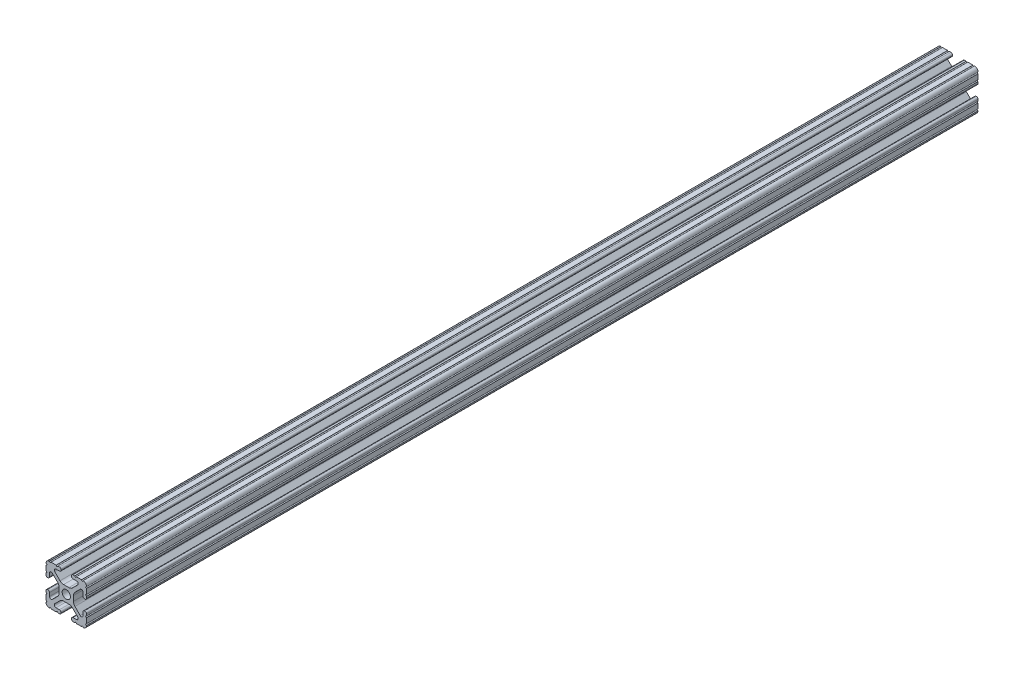
from build123d import *

# Parameters (mm, degrees)
SKETCH1_R           = 2.6035
BOSS_EXTRUDE1_DEPTH = 279.4


with BuildPart() as part:
    # Sketch1 → Boss-Extrude1 (new body, symmetric)
    with BuildSketch(Plane.XY):
        with BuildLine():
            Line((-7.179650497, -8.645192506), (-3.952270251, -5.423690499))
            ThreePointArc((-3.952270251, -5.423690499), (-2.922936451, -4.736929036), (-1.709253557, -4.4958))
            Line((-1.709253557, -4.4958), (1.709253557, -4.4958))
            ThreePointArc((1.709253557, -4.4958), (2.922936451, -4.736929036), (3.952270251, -5.423690499))
            Line((3.952270251, -5.423690499), (7.179650497, -8.645192506))
            ThreePointArc((7.179650497, -8.645192506), (7.41473083, -9.822813117), (6.416408329, -10.4902))
            Line((6.416408329, -10.4902), (4.287512407, -10.4902))
            ThreePointArc((4.287512407, -10.4902), (3.54574862, -10.79744862), (3.2385, -11.539212407))
            Line((3.2385, -11.539212407), (3.2385, -11.650987593))
            ThreePointArc((3.2385, -11.650987593), (3.54574862, -12.39275138), (4.287512407, -12.7))
            Line((4.287512407, -12.7), (5.317126718, -12.7))
            ThreePointArc((5.317126718, -12.7), (5.825126718, -12.192), (6.333126718, -12.7))
            Line((6.333126718, -12.7), (9.550443118, -12.7))
            ThreePointArc((9.550443118, -12.7), (10.058366869, -12.192000006), (10.566443095, -12.699847501))
            ThreePointArc((10.566443095, -12.699847501), (12.082537762, -12.08250727), (12.699846982, -10.566399977))
            ThreePointArc((12.699846982, -10.566399977), (12.192000006, -10.058323491), (12.7, -9.5504))
            Line((12.7, -9.5504), (12.7, -6.3330836))
            ThreePointArc((12.7, -6.3330836), (12.192, -5.8250836), (12.7, -5.3170836))
            Line((12.7, -5.3170836), (12.7, -4.287469289))
            ThreePointArc((12.7, -4.287469289), (12.39275138, -3.545705502), (11.650987593, -3.238456882))
            Line((11.650987593, -3.238456882), (11.539212407, -3.238456882))
            ThreePointArc((11.539212407, -3.238456882), (10.79744862, -3.545705502), (10.4902, -4.287469289))
            Line((10.4902, -4.287469289), (10.4902, -6.402089023))
            ThreePointArc((10.4902, -6.402089023), (9.856505071, -7.351067942), (8.737131347, -7.129408934))
            Line((8.737131347, -7.129408934), (5.441005833, -3.840816462))
            ThreePointArc((5.441005833, -3.840816462), (4.750877967, -2.809883091), (4.5085, -1.593185507))
            Line((4.5085, -1.593185507), (4.5085, 1.593185507))
            ThreePointArc((4.5085, 1.593185507), (4.750877967, 2.809883091), (5.441005833, 3.840816462))
            Line((5.441005833, 3.840816462), (8.737131347, 7.129408934))
            ThreePointArc((8.737131347, 7.129408934), (9.856505071, 7.351067942), (10.4902, 6.402089023))
            Line((10.4902, 6.402089023), (10.4902, 4.287469289))
            ThreePointArc((10.4902, 4.287469289), (10.79744862, 3.545705502), (11.539212407, 3.238456882))
            Line((11.539212407, 3.238456882), (11.650987593, 3.238456882))
            ThreePointArc((11.650987593, 3.238456882), (12.39275138, 3.545705502), (12.7, 4.287469289))
            Line((12.7, 4.287469289), (12.7, 5.3170836))
            ThreePointArc((12.7, 5.3170836), (12.192, 5.8250836), (12.7, 6.3330836))
            Line((12.7, 6.3330836), (12.7, 9.5504))
            ThreePointArc((12.7, 9.5504), (12.192000006, 10.058323491), (12.699846982, 10.566399977))
            ThreePointArc((12.699846982, 10.566399977), (12.082537762, 12.08250727), (10.566443095, 12.699847501))
            ThreePointArc((10.566443095, 12.699847501), (10.058366869, 12.192000006), (9.550443118, 12.7))
            Line((9.550443118, 12.7), (6.333126718, 12.7))
            ThreePointArc((6.333126718, 12.7), (5.825126718, 12.192), (5.317126718, 12.7))
            Line((5.317126718, 12.7), (4.287512407, 12.7))
            ThreePointArc((4.287512407, 12.7), (3.54574862, 12.39275138), (3.2385, 11.650987593))
            Line((3.2385, 11.650987593), (3.2385, 11.539212407))
            ThreePointArc((3.2385, 11.539212407), (3.54574862, 10.79744862), (4.287512407, 10.4902))
            Line((4.287512407, 10.4902), (6.476788598, 10.4902))
            ThreePointArc((6.476788598, 10.4902), (7.432222385, 9.85140422), (7.207036008, 8.724370562))
            Line((7.207036008, 8.724370562), (3.898272566, 5.423169045))
            ThreePointArc((3.898272566, 5.423169045), (2.869120213, 4.736787962), (1.655778399, 4.4958))
            Line((1.655778399, 4.4958), (-1.655778399, 4.4958))
            ThreePointArc((-1.655778399, 4.4958), (-2.869120213, 4.736787962), (-3.898272566, 5.423169045))
            Line((-3.898272566, 5.423169045), (-7.207036008, 8.724370562))
            ThreePointArc((-7.207036008, 8.724370562), (-7.432222385, 9.85140422), (-6.476788598, 10.4902))
            Line((-6.476788598, 10.4902), (-4.287512407, 10.4902))
            ThreePointArc((-4.287512407, 10.4902), (-3.54574862, 10.79744862), (-3.2385, 11.539212407))
            Line((-3.2385, 11.539212407), (-3.2385, 11.650987593))
            ThreePointArc((-3.2385, 11.650987593), (-3.54574862, 12.39275138), (-4.287512407, 12.7))
            Line((-4.287512407, 12.7), (-5.317126718, 12.7))
            ThreePointArc((-5.317126718, 12.7), (-5.825126718, 12.192), (-6.333126718, 12.7))
            Line((-6.333126718, 12.7), (-9.550443118, 12.7))
            ThreePointArc((-9.550443118, 12.7), (-10.058366869, 12.192000006), (-10.566443095, 12.699847501))
            ThreePointArc((-10.566443095, 12.699847501), (-12.082537762, 12.08250727), (-12.699846982, 10.566399977))
            ThreePointArc((-12.699846982, 10.566399977), (-12.192000006, 10.058323491), (-12.7, 9.5504))
            Line((-12.7, 9.5504), (-12.7, 6.3330836))
            ThreePointArc((-12.7, 6.3330836), (-12.192, 5.8250836), (-12.7, 5.3170836))
            Line((-12.7, 5.3170836), (-12.7, 4.287469289))
            ThreePointArc((-12.7, 4.287469289), (-12.39275138, 3.545705502), (-11.650987593, 3.238456882))
            Line((-11.650987593, 3.238456882), (-11.539212407, 3.238456882))
            ThreePointArc((-11.539212407, 3.238456882), (-10.79744862, 3.545705502), (-10.4902, 4.287469289))
            Line((-10.4902, 4.287469289), (-10.4902, 6.402089023))
            ThreePointArc((-10.4902, 6.402089023), (-9.856505071, 7.351067942), (-8.737131347, 7.129408934))
            Line((-8.737131347, 7.129408934), (-5.441005833, 3.840816462))
            ThreePointArc((-5.441005833, 3.840816462), (-4.750877967, 2.809883091), (-4.5085, 1.593185507))
            Line((-4.5085, 1.593185507), (-4.5085, -1.593185507))
            ThreePointArc((-4.5085, -1.593185507), (-4.750877967, -2.809883091), (-5.441005833, -3.840816462))
            Line((-5.441005833, -3.840816462), (-8.737131347, -7.129408934))
            ThreePointArc((-8.737131347, -7.129408934), (-9.856505071, -7.351067942), (-10.4902, -6.402089023))
            Line((-10.4902, -6.402089023), (-10.4902, -4.287469289))
            ThreePointArc((-10.4902, -4.287469289), (-10.79744862, -3.545705502), (-11.539212407, -3.238456882))
            Line((-11.539212407, -3.238456882), (-11.650987593, -3.238456882))
            ThreePointArc((-11.650987593, -3.238456882), (-12.39275138, -3.545705502), (-12.7, -4.287469289))
            Line((-12.7, -4.287469289), (-12.7, -5.3170836))
            ThreePointArc((-12.7, -5.3170836), (-12.192, -5.8250836), (-12.7, -6.3330836))
            Line((-12.7, -6.3330836), (-12.7, -9.5504))
            ThreePointArc((-12.7, -9.5504), (-12.192000006, -10.058323491), (-12.699846982, -10.566399977))
            ThreePointArc((-12.699846982, -10.566399977), (-12.082537762, -12.08250727), (-10.566443095, -12.699847501))
            ThreePointArc((-10.566443095, -12.699847501), (-10.058366869, -12.192000006), (-9.550443118, -12.7))
            Line((-9.550443118, -12.7), (-6.333126718, -12.7))
            ThreePointArc((-6.333126718, -12.7), (-5.825126718, -12.192), (-5.317126718, -12.7))
            Line((-5.317126718, -12.7), (-4.287512407, -12.7))
            ThreePointArc((-4.287512407, -12.7), (-3.54574862, -12.39275138), (-3.2385, -11.650987593))
            Line((-3.2385, -11.650987593), (-3.2385, -11.539212407))
            ThreePointArc((-3.2385, -11.539212407), (-3.54574862, -10.79744862), (-4.287512407, -10.4902))
            Line((-4.287512407, -10.4902), (-6.416408329, -10.4902))
            ThreePointArc((-6.416408329, -10.4902), (-7.41473083, -9.822813117), (-7.179650497, -8.645192506))
        make_face()
        Circle(SKETCH1_R, mode=Mode.SUBTRACT)
    extrude(amount=BOSS_EXTRUDE1_DEPTH, both=True)


solid = part.part
